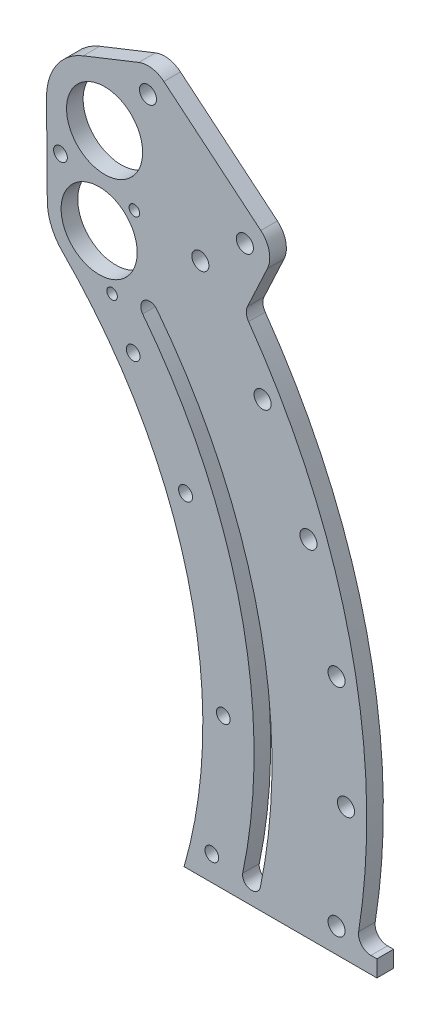
from build123d import *

# Parameters (mm, degrees)
SKETCH1_R           = 2.6289
SKETCH1_R_2         = 2.667
SKETCH1_R_3         = 3.2639
BOSS_EXTRUDE1_DEPTH = 6.35
SKETCH3_R           = 14.5542
SKETCH3_R_2         = 3.2639
SKETCH3_R_3         = 2.6289
BOSS_EXTRUDE2_DEPTH = 6.35
SKETCH4_R           = 14.5542
SKETCH4_R_2         = 2.0193
CUT_EXTRUDE1_DEPTH  = 7.35
BOSS_EXTRUDE3_DEPTH = 6.35
FILLET1_R           = 4.7625
FILLET2_R           = 4.7625


with BuildPart() as part:
    # Sketch1 → Boss-Extrude1 (new body)
    with BuildSketch(Plane.XY):
        with BuildLine():
            Line((176.178529946, -50.8), (240.761529124, -50.8))
            ThreePointArc((240.761529124, -50.8), (235.877364624, 70.061564101), (173.992462346, 173.992462346))
            Line((173.992462346, 173.992462346), (129.652447748, 129.652447748))
            ThreePointArc((129.652447748, 129.652447748), (169.399086533, 70.167399096), (183.35625, 0))
            ThreePointArc((183.35625, 0), (181.552952325, -25.652288715), (176.178529946, -50.8))
        make_face()
        with Locations((191.177219016, 6.676055597)):
            Circle(SKETCH1_R, mode=Mode.SUBTRACT)
        with Locations((156.698666372, 109.721587421)):
            Circle(SKETCH1_R, mode=Mode.SUBTRACT)
        with Locations((176.732380322, 73.20494884)):
            Circle(SKETCH1_R_2, mode=Mode.SUBTRACT)
        with Locations((186.787775735, -41.275)):
            Circle(SKETCH1_R, mode=Mode.SUBTRACT)
        with Locations((238.125, 0)):
            Circle(SKETCH1_R_3, mode=Mode.SUBTRACT)
        with Locations((234.507346186, 41.349972307)):
            Circle(SKETCH1_R_3, mode=Mode.SUBTRACT)
        with Locations((223.764305325, 81.443546629)):
            Circle(SKETCH1_R_3, mode=Mode.SUBTRACT)
        with Locations((206.222299276, 119.0625)):
            Circle(SKETCH1_R_3, mode=Mode.SUBTRACT)
        with Locations((182.414333018, 153.063799557)):
            Circle(SKETCH1_R_3, mode=Mode.SUBTRACT)
        with Locations((234.507346186, -41.349972307)):
            Circle(SKETCH1_R_3, mode=Mode.SUBTRACT)
        with BuildLine():
            ThreePointArc((202.946, 0), (201.859935486, -20.967721902), (198.61336608, -41.711026485))
            ThreePointArc((198.61336608, -41.711026485), (201.391341659, -45.688667392), (205.368929989, -42.910616532))
            ThreePointArc((205.368929989, -42.910616532), (208.692287116, -21.569601625), (209.804, 0))
            ThreePointArc((209.804, 0), (198.481076932, 67.99250338), (165.734482585, 128.646024805))
            ThreePointArc((165.734482585, 128.646024805), (160.923178893, 129.252192093), (160.317011605, 124.440888401))
            ThreePointArc((160.317011605, 124.440888401), (191.993196693, 65.769988136), (202.946, 0))
        make_face(mode=Mode.SUBTRACT)
    extrude(amount=BOSS_EXTRUDE1_DEPTH)

    # Sketch3 → Boss-Extrude2 (add)
    with BuildSketch(Plane.XY.offset(6.35)):
        with BuildLine():
            Line((129.652447748, 129.652447748), (161.644610179, 161.644610179))
            Line((161.644610179, 161.644610179), (173.992462346, 173.992462346))
            ThreePointArc((173.992462346, 173.992462346), (187.203995727, 159.691633751), (199.243521921, 144.391041546))
            Line((199.243521921, 144.391041546), (208.072252438, 163.324315239))
            ThreePointArc((208.072252438, 163.324315239), (208.734128286, 169.432705073), (205.528624059, 174.674388835))
            Line((205.528624059, 174.674388835), (168.450190134, 205.497612521))
            ThreePointArc((168.450190134, 205.497612521), (163.856747392, 207.579840958), (158.844030643, 207.024807371))
            Line((158.844030643, 207.024807371), (137.554097629, 198.565416651))
            ThreePointArc((137.554097629, 198.565416651), (127.316076149, 190.310286973), (123.536791738, 177.713411997))
            Line((123.536791738, 177.713411997), (123.841133335, 143.507548105))
            ThreePointArc((123.841133335, 143.507548105), (125.38482655, 136.008742521), (129.652447748, 129.652447748))
        make_face()
        with Locations((145.760912093, 177.911147809)):
            Circle(SKETCH3_R, mode=Mode.SUBTRACT)
        with Locations((199.439670766, 167.349754182)):
            Circle(SKETCH3_R_2, mode=Mode.SUBTRACT)
        with Locations((162.361236841, 198.172977868)):
            Circle(SKETCH3_R_2, mode=Mode.SUBTRACT)
        with Locations((128.876648593, 161.759110908)):
            Circle(SKETCH3_R_3, mode=Mode.SUBTRACT)
    extrude(amount=-BOSS_EXTRUDE2_DEPTH)

    # Sketch4 → Cut-Extrude1 (cut, through all)
    with BuildSketch(Plane.XY.offset(6.35)):
        with Locations((143.684097937, 143.684097937)):
            Circle(SKETCH4_R)
        with Locations((157.154482119, 157.154482119)):
            Circle(SKETCH4_R_2)
        with Locations((148.614600746, 125.283210946)):
            Circle(SKETCH4_R_2)
    extrude(amount=-CUT_EXTRUDE1_DEPTH, mode=Mode.SUBTRACT)

    # Sketch5 → Boss-Extrude3 (add)
    with BuildSketch(Plane.XY.offset(6.35)):
        with BuildLine():
            Line((240.761529124, -50.8), (249.951861983, -50.8))
            Line((249.951861983, -50.8), (249.951861983, -44.45))
            Line((249.951861983, -44.45), (242.014361983, -44.45))
            ThreePointArc((242.014361983, -44.45), (241.408825198, -47.629119481), (240.761529124, -50.8))
        make_face()
    extrude(amount=-BOSS_EXTRUDE3_DEPTH)

    # Fillet1
    fillet1_edges = [part.edges().sort_by_distance(p)[0] for p in [
        (242.014361983, -44.45, 3.175),
    ]]
    fillet(fillet1_edges, radius=FILLET1_R)

    # Fillet2
    fillet2_edges = [part.edges().sort_by_distance(p)[0] for p in [
        (199.243521921, 144.391041546, 3.175),
    ]]
    fillet(fillet2_edges, radius=FILLET2_R)


solid = part.part
